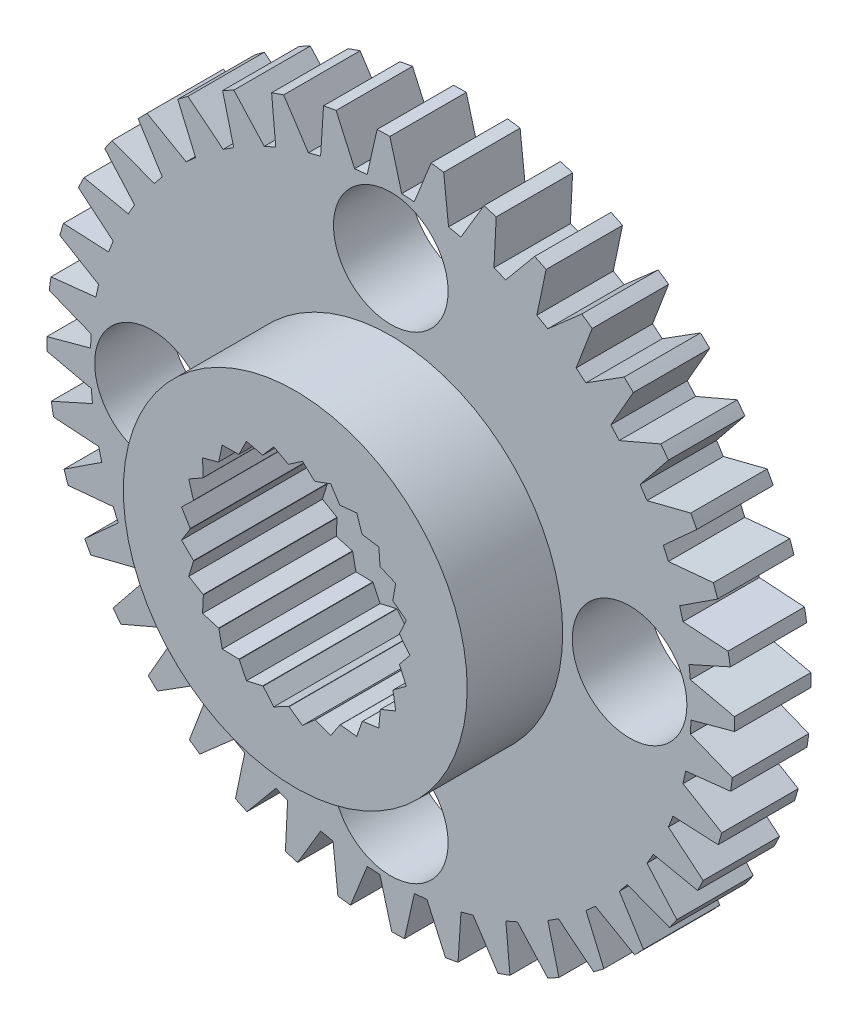
from build123d import *

# Parameters (mm, degrees)
SKETCH1_R           = 9
SKETCH1_R_2         = 1.5
SKETCH1_R_3         = 4.5
BOSS_EXTRUDE1_DEPTH = 2
SKETCH1_2_R         = 4.5
BOSS_EXTRUDE2_DEPTH = 4.5
SKETCH2_R           = 1.5
CUT_EXTRUDE1_DEPTH  = 4.5
SKETCH3_R           = 2.75
CUT_EXTRUDE2_DEPTH  = 3.5
CUT_EXTRUDE3_DEPTH  = 3.5
CIRPATTERN1_COUNT   = 25
BOSS_EXTRUDE3_START = 3
SKETCH5_R           = 3.5
SKETCH5_R_2         = 1.5
BOSS_EXTRUDE3_DEPTH = 3
CUT_EXTRUDE11_START = -3.6
CUT_EXTRUDE11_DEPTH = 3.6
CIRPATTERN4_COUNT   = 40


with BuildPart() as part:
    # Sketch1 → Boss-Extrude1 (new body)
    with BuildSketch(Plane.XY):
        Circle(SKETCH1_R)
        with Locations((0, 6.25)):
            Circle(SKETCH1_R_2, mode=Mode.SUBTRACT)
        with Locations((6.25, 0)):
            Circle(SKETCH1_R_2, mode=Mode.SUBTRACT)
        with Locations((0, -6.25)):
            Circle(SKETCH1_R_2, mode=Mode.SUBTRACT)
        with Locations((-6.25, 0)):
            Circle(SKETCH1_R_2, mode=Mode.SUBTRACT)
        Circle(SKETCH1_R_3, mode=Mode.SUBTRACT)
    extrude(amount=BOSS_EXTRUDE1_DEPTH)

    # Sketch1_2 → Boss-Extrude2 (add)
    with BuildSketch(Plane.XY):
        Circle(SKETCH1_2_R)
    extrude(amount=BOSS_EXTRUDE2_DEPTH)

    # Sketch2 → Cut-Extrude1 (cut)
    with BuildSketch(Plane(origin=(0, 0, 0), x_dir=(-1, 0, 0), z_dir=(0, 0, -1))):
        Circle(SKETCH2_R)
    extrude(amount=-CUT_EXTRUDE1_DEPTH, mode=Mode.SUBTRACT)

    # Sketch3 → Cut-Extrude2 (cut)
    with BuildSketch(Plane.XY.offset(4.5)):
        Circle(SKETCH3_R)
    extrude(amount=-CUT_EXTRUDE2_DEPTH, mode=Mode.SUBTRACT)

    # Sketch4 → Cut-Extrude3 (cut)
    with BuildSketch(Plane.XY.offset(4.5)):
        with BuildLine():
            Line((-2.976344104, 0.375999701), (-2.75, 0))
            ThreePointArc((-2.75, 0), (-2.728912829, 0.339904061), (-2.665974712, 0.674595311))
            Line((-2.665974712, 0.674595311), (-2.976344104, 0.375999701))
        make_face()
    cut_extrude3 = extrude(amount=-CUT_EXTRUDE3_DEPTH, mode=Mode.SUBTRACT)

    # CirPattern1: Cut-Extrude3 ×25 about axis
    cirpattern1_axis = Axis((0, 0, 4.5), (0, 0, -1))
    for i in range(1, CIRPATTERN1_COUNT):
        add(cut_extrude3.rotate(cirpattern1_axis, i * 360 / CIRPATTERN1_COUNT), mode=Mode.SUBTRACT)

    # Sketch5 → Boss-Extrude3 (add)
    with BuildSketch(Plane(origin=(0, 0, 0), x_dir=(-1, 0, 0), z_dir=(0, 0, -1)).offset(BOSS_EXTRUDE3_START)):
        Circle(SKETCH5_R)
        Circle(SKETCH5_R_2, mode=Mode.SUBTRACT)
    extrude(amount=-BOSS_EXTRUDE3_DEPTH)

    # Sketch7 → Cut-Extrude11 (cut)
    with BuildSketch(Plane.XY.offset(2).offset(CUT_EXTRUDE11_START)):
        with BuildLine():
            Line((-7.295133166, 5.270771489), (-6.18947521, 4.850239676))
            Line((-6.18947521, 4.850239676), (-5.980523997, 5.105659703))
            Line((-5.980523997, 5.105659703), (-6.611805814, 6.106064516))
            ThreePointArc((-6.611805814, 6.106064516), (-6.79195863, 5.905023113), (-6.966000974, 5.698669181))
            ThreePointArc((-6.966000974, 5.698669181), (-7.133776058, 5.487188638), (-7.295133166, 5.270771489))
        make_face()
    cut_extrude11 = extrude(amount=CUT_EXTRUDE11_DEPTH, mode=Mode.SUBTRACT)

    # CirPattern4: Cut-Extrude11 ×40 about axis
    cirpattern4_axis = Axis((0, 0, 2), (0, 0, -1))
    for i in range(1, CIRPATTERN4_COUNT):
        add(cut_extrude11.rotate(cirpattern4_axis, i * 360 / CIRPATTERN4_COUNT), mode=Mode.SUBTRACT)


solid = part.part
